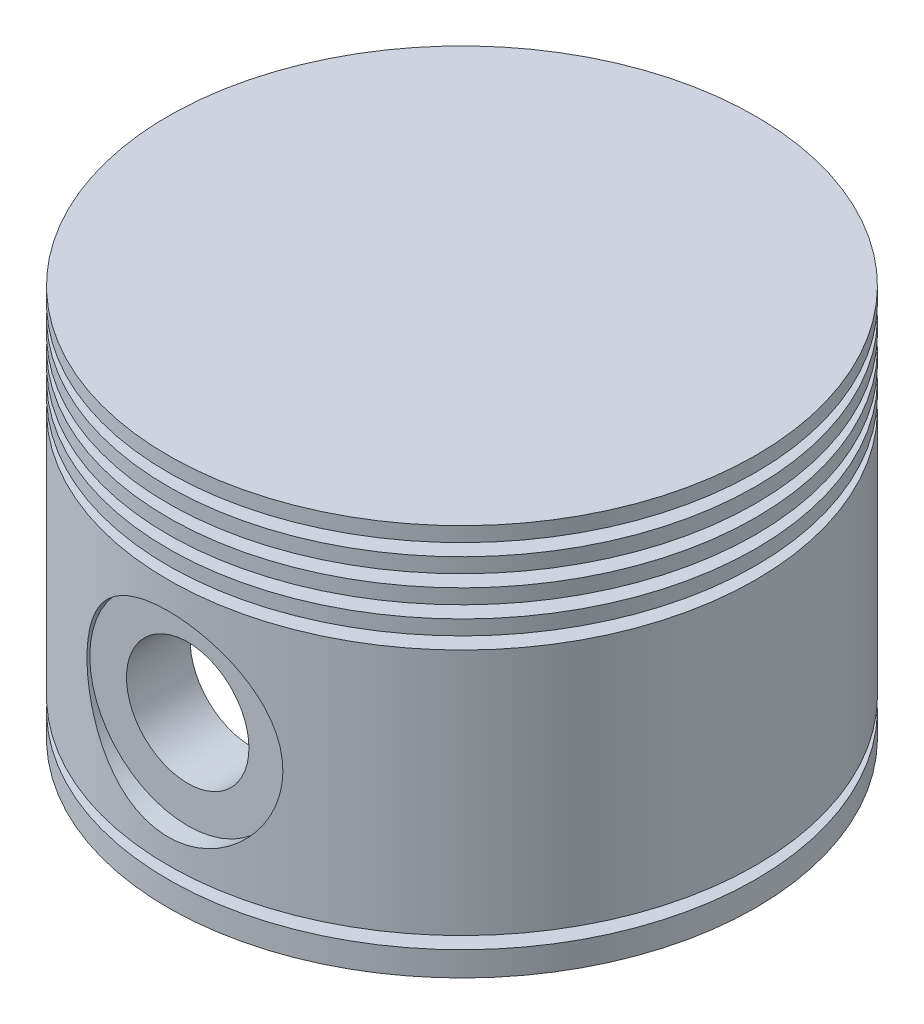
from build123d import *

# Parameters (mm, degrees)
SKETCH2_R               = 25
CUT_EXTRUDE1_DEPTH      = 35
SKETCH3_R               = 10
SKETCH3_R_2             = 6.25
CUT_EXTRUDE2_DEPTH      = 2
CUT_EXTRUDE3_REACH      = 80.102
CUT_EXTRUDE3_END_RADIUS = 25
SKETCH3_2_R             = 6.25
BOSS_EXTRUDE1_START     = -2
SKETCH3_3_R             = 10
SKETCH3_3_R_2           = 6.25
BOSS_EXTRUDE1_DEPTH     = 6.5
BOSS_EXTRUDE2_START     = -58
SKETCH3_4_R             = 10
SKETCH3_4_R_2           = 6.25
BOSS_EXTRUDE2_DEPTH     = 6.5


with BuildPart() as part:
    # Sketch1 → Revolve1 (revolve)
    with BuildSketch(Plane.XY, mode=Mode.PRIVATE) as revolve1_sk:
        Polygon((-30, 0), (0, 0), (0, 40), (-30, 40), (-30, 38.5), (-28, 38.5), (-28, 37.25), (-30, 37.25), (-30, 35.75), (-28, 35.75), (-28, 34.5), (-30, 34.5), (-30, 33), (-28, 33), (-28, 31.75), (-30, 31.75), (-30, 30.25), (-28, 30.25), (-28, 29), (-30, 29), (-30, 3.75), (-28, 3.75), (-28, 2.5), (-30, 2.5), align=None)
    revolve(revolve1_sk.sketch.rotate(Axis((0, 0, 0), (0, 1, 0)), 180), axis=Axis((0, 0, 0), (0, 1, 0)))

    # Sketch2 → Cut-Extrude1 (cut)
    with BuildSketch(Plane.XZ):
        Circle(SKETCH2_R)
    extrude(amount=-CUT_EXTRUDE1_DEPTH, mode=Mode.SUBTRACT)

    # Sketch3 → Cut-Extrude2 (cut)
    with BuildSketch(Plane.XY.offset(30)):
        with Locations((0, 16.25)):
            Circle(SKETCH3_R)
        with Locations((0, 16.25)):
            Circle(SKETCH3_R_2, mode=Mode.SUBTRACT)
    cut_extrude2 = extrude(amount=-CUT_EXTRUDE2_DEPTH, mode=Mode.SUBTRACT)

    # Cut-Extrude3: up to this cylinder (the profile starts outside it)
    cut_extrude3_end = Plane(origin=(0, 16.25, 0), z_dir=(0, -1, 0)) * Cylinder(CUT_EXTRUDE3_END_RADIUS, 211.204, mode=Mode.PRIVATE)
    # Sketch3_2 → Cut-Extrude3 (cut, up to the surface)
    with BuildSketch(Plane.XY.offset(30), mode=Mode.PRIVATE) as cut_extrude3_sk1:
        with Locations((0, 16.25)):
            Circle(SKETCH3_2_R)
    cut_extrude3_tool1 = extrude(cut_extrude3_sk1.sketch, amount=-CUT_EXTRUDE3_REACH, mode=Mode.PRIVATE) - cut_extrude3_end
    cut_extrude3 = cut_extrude3_tool1.solids().sort_by_distance((0, 16.25, 30))[0]
    add(cut_extrude3, mode=Mode.SUBTRACT)

    # Sketch3_3 → Boss-Extrude1 (add)
    with BuildSketch(Plane.XY.offset(30).offset(BOSS_EXTRUDE1_START)):
        with Locations((0, 16.25)):
            Circle(SKETCH3_3_R)
        with Locations((0, 16.25)):
            Circle(SKETCH3_3_R_2, mode=Mode.SUBTRACT)
    extrude(amount=-BOSS_EXTRUDE1_DEPTH)

    # Mirror1: Cut-Extrude2, Cut-Extrude3 across plane
    add(cut_extrude2.mirror(Plane.XY), mode=Mode.SUBTRACT)
    add(cut_extrude3.mirror(Plane.XY), mode=Mode.SUBTRACT)

    # Sketch3_4 → Boss-Extrude2 (add)
    with BuildSketch(Plane.XY.offset(30).offset(BOSS_EXTRUDE2_START)):
        with Locations((0, 16.25)):
            Circle(SKETCH3_4_R)
        with Locations((0, 16.25)):
            Circle(SKETCH3_4_R_2, mode=Mode.SUBTRACT)
    extrude(amount=BOSS_EXTRUDE2_DEPTH)


solid = part.part
